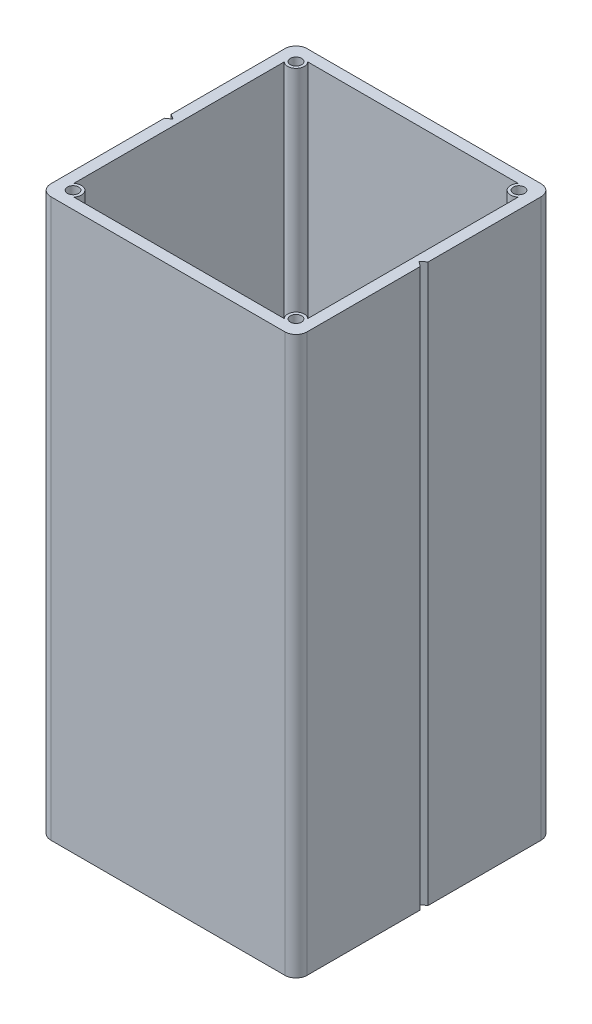
from build123d import *

# Parameters (mm, degrees)
SKETCH1_R           = 1
BOSS_EXTRUDE1_DEPTH = 100
FILLET1_R           = 2
CUT_EXTRUDE2_REACH  = 48
SKETCH3_R           = 1.5
FILLET2_R           = 2


with BuildPart() as part:
    # Sketch1 → Boss-Extrude1 (new body)
    with BuildSketch(Plane(origin=(0, 0, 0), x_dir=(1, 0, 0), z_dir=(0, 1, 0))):
        Polygon((-23, 0.601609353), (-22.074492009, 0), (-23, -0.601609353), (-23, -23), (23, -23), (23, -0.712327005), (22.071835016, 0), (23, 0.712327005), (23, 23), (-23, 23), align=None)
        with Locations((-20, 20)):
            Circle(SKETCH1_R, mode=Mode.SUBTRACT)
        with Locations((20, 20)):
            Circle(SKETCH1_R, mode=Mode.SUBTRACT)
        with Locations((20, -20)):
            Circle(SKETCH1_R, mode=Mode.SUBTRACT)
        with Locations((-20, -20)):
            Circle(SKETCH1_R, mode=Mode.SUBTRACT)
        with BuildLine():
            Line((-18.881966011, 21), (18.881966011, 21))
            ThreePointArc((18.881966011, 21), (18.939339828, 18.939339828), (21, 18.881966011))
            Line((21, 18.881966011), (21, -18.881966011))
            ThreePointArc((21, -18.881966011), (18.939339828, -18.939339828), (18.881966011, -21))
            Line((18.881966011, -21), (-18.881966011, -21))
            ThreePointArc((-18.881966011, -21), (-18.939339828, -18.939339828), (-21, -18.881966011))
            Line((-21, -18.881966011), (-21, 18.881966011))
            ThreePointArc((-21, 18.881966011), (-18.939339828, 18.939339828), (-18.881966011, 21))
        make_face(mode=Mode.SUBTRACT)
    extrude(amount=BOSS_EXTRUDE1_DEPTH)

    # Fillet1
    fillet1_edges = [part.edges().sort_by_distance(p)[0] for p in [
        (-23, 50, -23),
        (23, 50, -23),
    ]]
    fillet(fillet1_edges, radius=FILLET1_R)

    # Sketch3 → Cut-Extrude2 (cut, up to next)
    with BuildSketch(Plane(origin=(0, 0, -23), x_dir=(-1, 0, 0), z_dir=(0, 0, -1)), mode=Mode.PRIVATE) as cut_extrude2_sk1:
        with Locations((8, 50)):
            Circle(SKETCH3_R)
    cut_extrude2_tool1 = extrude(cut_extrude2_sk1.sketch, amount=-CUT_EXTRUDE2_REACH, mode=Mode.PRIVATE) & part.part
    add(cut_extrude2_tool1.solids().sort_by_distance((-8, 50, -23))[0], mode=Mode.SUBTRACT)
    # Sketch3 → Cut-Extrude2 (cut, up to next)
    with BuildSketch(Plane(origin=(0, 0, -23), x_dir=(-1, 0, 0), z_dir=(0, 0, -1)), mode=Mode.PRIVATE) as cut_extrude2_sk2:
        with Locations((-8, 50)):
            Circle(SKETCH3_R)
    cut_extrude2_tool2 = extrude(cut_extrude2_sk2.sketch, amount=-CUT_EXTRUDE2_REACH, mode=Mode.PRIVATE) & part.part
    add(cut_extrude2_tool2.solids().sort_by_distance((8, 50, -23))[0], mode=Mode.SUBTRACT)

    # Fillet2
    fillet2_edges = [part.edges().sort_by_distance(p)[0] for p in [
        (23, 50, 23),
        (-23, 50, 23),
    ]]
    fillet(fillet2_edges, radius=FILLET2_R)


solid = part.part
